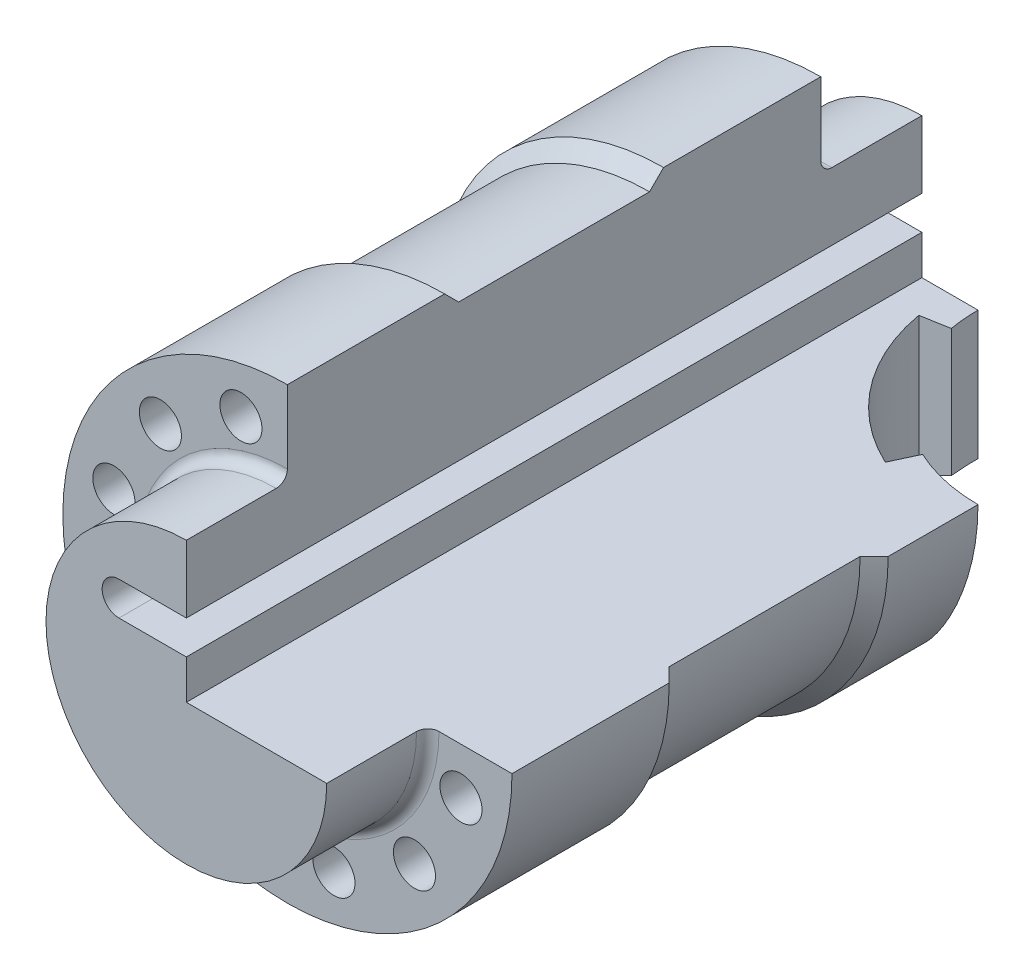
from build123d import *

# Parameters (mm, degrees)
CUT_EXTRUDE1_DEPTH      = 66.5
CUT_EXTRUDE1_DEPTH_BACK = 66.5
CUT_EXTRUDE3_DEPTH      = 41
SKETCH4_R               = 3.75
CUT_EXTRUDE4_DEPTH      = 66.5000001
CUT_EXTRUDE4_DEPTH_BACK = 66.5000001


with BuildPart() as part:
    # Sketch1 → Revolve1 (revolve)
    with BuildSketch(Plane(origin=(0, 0, 0), x_dir=(0, 0, -1), z_dir=(1, 0, 0))):
        with BuildLine():
            Line((65.5, 0), (-65.5, 0))
            Line((-65.5, 0), (-65.5, 25))
            Line((-65.5, 25), (-49.5, 25))
            ThreePointArc((-49.5, 25), (-48.085786438, 25.585786438), (-47.5, 27))
            Line((-47.5, 27), (-47.5, 40))
            Line((-47.5, 40), (-19.5, 40))
            Line((-19.5, 40), (-17, 37.5))
            Line((-17, 37.5), (17, 37.5))
            Line((17, 37.5), (19.5, 40))
            Line((19.5, 40), (47.5, 40))
            Line((47.5, 40), (47.5, 27))
            ThreePointArc((47.5, 27), (48.085786438, 25.585786438), (49.5, 25))
            Line((49.5, 25), (65.5, 25))
            Line((65.5, 25), (65.5, 0))
        make_face()
    revolve(axis=Axis((0, 0, -65.5), (0, 0, 1)))

    # Sketch2 → Cut-Extrude1 (cut, two sides)
    with BuildSketch(Plane.XY) as cut_extrude1_sk:
        with BuildLine():
            Line((0, 40), (0, 13))
            Line((0, 13), (-12, 13))
            ThreePointArc((-12, 13), (-15, 10), (-12, 7))
            Line((-12, 7), (0, 7))
            Line((0, 7), (0, 0))
            Line((0, 0), (40, 0))
            ThreePointArc((40, 0), (28.284271247, 28.284271247), (0, 40))
        make_face()
    extrude(amount=CUT_EXTRUDE1_DEPTH, mode=Mode.SUBTRACT)
    extrude(cut_extrude1_sk.sketch, amount=-CUT_EXTRUDE1_DEPTH_BACK, mode=Mode.SUBTRACT)

    # Sketch3 → Cut-Extrude3 (cut, through all)
    with BuildSketch(Plane(origin=(0, 0, 0), x_dir=(1, 0, 0), z_dir=(0, 1, 0))):
        with BuildLine():
            Line((27.321452148, 38.310766389), (25.208360839, 33.779227454))
            ThreePointArc((25.208360839, 33.779227454), (12.23263309, 44.193349985), (5.531728645, 59.422313782))
            Line((5.531728645, 59.422313782), (10.45576741, 60.29055467))
            ThreePointArc((10.45576741, 60.29055467), (63.800600209, 83.76284287), (27.321452148, 38.310766389))
        make_face()
    extrude(amount=-CUT_EXTRUDE3_DEPTH, mode=Mode.SUBTRACT)

    # Sketch4 → Cut-Extrude4 (cut, two sides)
    with BuildSketch(Plane.XY) as cut_extrude4_sk:
        with Locations((-8.282209443, 30.909626441)):
            Circle(SKETCH4_R)
        with Locations((8.282209443, 30.909626441)):
            Circle(SKETCH4_R)
        with Locations((22.627416998, 22.627416998)):
            Circle(SKETCH4_R)
        with Locations((30.909626441, 8.282209443)):
            Circle(SKETCH4_R)
        with Locations((30.909626441, -8.282209443)):
            Circle(SKETCH4_R)
        with Locations((22.627416998, -22.627416998)):
            Circle(SKETCH4_R)
        with Locations((8.282209443, -30.909626441)):
            Circle(SKETCH4_R)
        with Locations((-8.282209443, -30.909626441)):
            Circle(SKETCH4_R)
        with Locations((-22.627416998, -22.627416998)):
            Circle(SKETCH4_R)
        with Locations((-30.909626441, -8.282209443)):
            Circle(SKETCH4_R)
        with Locations((-30.909626441, 8.282209443)):
            Circle(SKETCH4_R)
        with Locations((-22.627416998, 22.627416998)):
            Circle(SKETCH4_R)
    extrude(amount=CUT_EXTRUDE4_DEPTH, mode=Mode.SUBTRACT)
    extrude(cut_extrude4_sk.sketch, amount=-CUT_EXTRUDE4_DEPTH_BACK, mode=Mode.SUBTRACT)


solid = part.part
